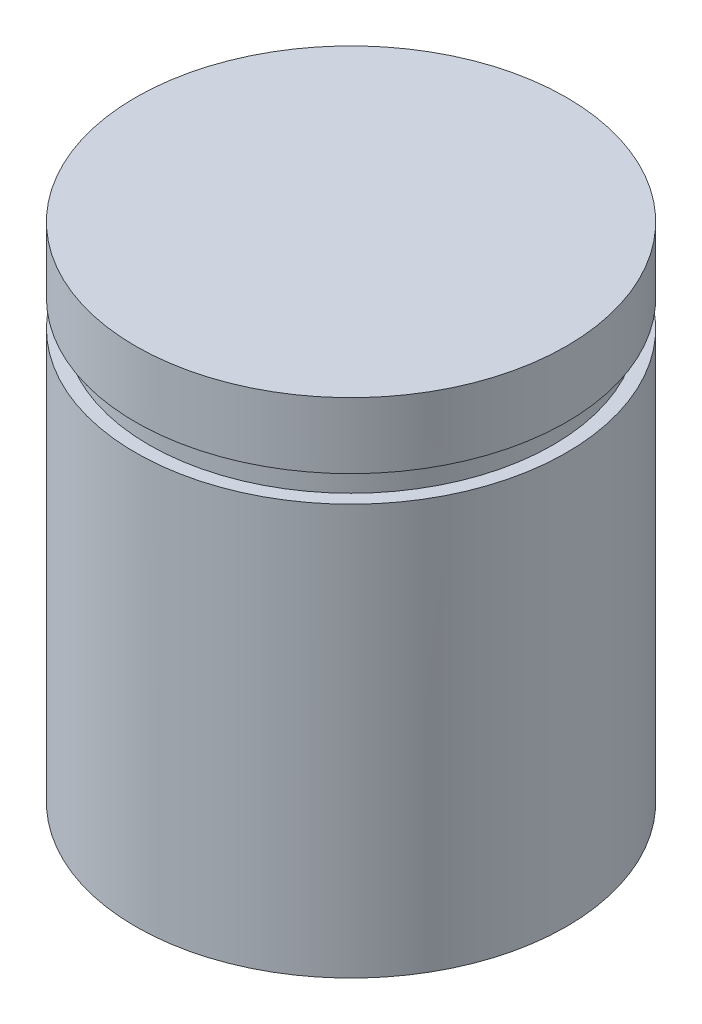
from build123d import *

# Parameters (mm, degrees)
SKETCH1_R           = 6
BOSS_EXTRUDE1_DEPTH = 14
SKETCH2_R           = 5.6261
CUT_EXTRUDE1_DEPTH  = 0.7366


with BuildPart() as part:
    # Sketch1 → Boss-Extrude1 (new body)
    with BuildSketch(Plane(origin=(0, 0, 0), x_dir=(1, 0, 0), z_dir=(0, 1, 0))):
        Circle(SKETCH1_R)
    extrude(amount=BOSS_EXTRUDE1_DEPTH)

    # Sketch2 → Cut-Extrude1 (cut)
    with BuildSketch(Plane(origin=(0, 11.43, 0), x_dir=(-1, 0, 0), z_dir=(0, -1, 0))):
        Polygon((-7.456726378, 6.985786616), (-7.456726378, -7.652827554), (9.78325703, -7.652827554), (9.78325703, 8.499310536), align=None)
        Circle(SKETCH2_R, mode=Mode.SUBTRACT)
    extrude(amount=-CUT_EXTRUDE1_DEPTH, mode=Mode.SUBTRACT)


solid = part.part
